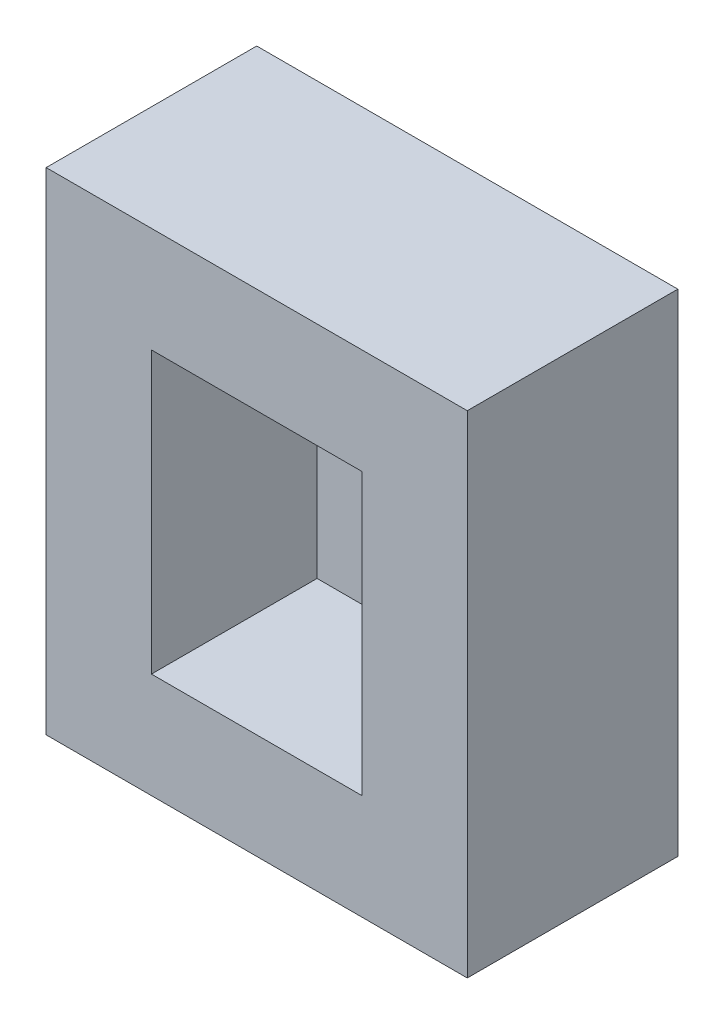
from build123d import *

# Parameters (mm, degrees)
SKETCH1_W   = 609.6
SKETCH1_H   = 304.8
FRAME_DEPTH = 711.2
SKETCH2_W   = 304.8
SKETCH2_H   = 406.4
SPACE_DEPTH = 239.776


with BuildPart() as part:
    # Sketch1 → Frame (new body)
    with BuildSketch(Plane(origin=(0, 0, 0), x_dir=(1, 0, 0), z_dir=(0, 1, 0))):
        with Locations((304.8, 152.4)):
            Rectangle(SKETCH1_W, SKETCH1_H)
    extrude(amount=FRAME_DEPTH)

    # Sketch2 → Space (cut)
    with BuildSketch(Plane.XY):
        with Locations((304.8, 355.6)):
            Rectangle(SKETCH2_W, SKETCH2_H)
    extrude(amount=-SPACE_DEPTH, mode=Mode.SUBTRACT)


solid = part.part
